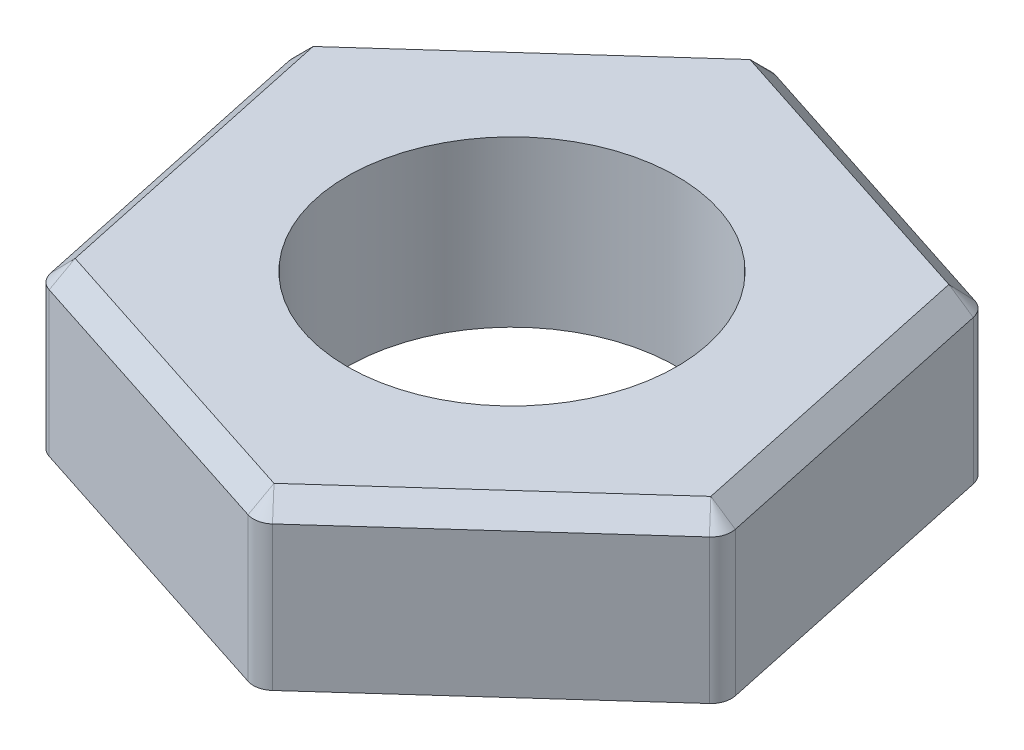
from build123d import *

# Parameters (mm, degrees)
BOSS_EXTRUDE1_DEPTH     = 4
FILLET1_R               = 0.5
CHAMFER1_SIZE           = 0.5
CUT_EXTRUDE1_DEPTH      = 4
CUT_EXTRUDE1_DEPTH_BACK = 4
SKETCH2_R               = 4


with BuildPart() as part:
    # Sketch1 → Boss-Extrude1 (new body)
    with BuildSketch(Plane(origin=(0, 0, 0), x_dir=(1, 0, 0), z_dir=(0, 1, 0))):
        Polygon((6.003079224, 5.412612415), (-1.68592024, 7.905125317), (-7.688999465, 2.492512902), (-6.003079224, -5.412612415), (1.68592024, -7.905125317), (7.688999465, -2.492512902), align=None)
    extrude(amount=BOSS_EXTRUDE1_DEPTH)

    # Fillet1
    fillet1_edges = [part.edges().sort_by_distance(p)[0] for p in [
        (7.688999465, 2, 2.492512902),
        (-6.003079224, 2, 5.412612415),
        (-7.688999465, 2, -2.492512902),
        (-1.68592024, 2, -7.905125317),
        (6.003079224, 2, -5.412612415),
        (1.68592024, 2, 7.905125317),
    ]]
    fillet(fillet1_edges, radius=FILLET1_R)

    # Chamfer1
    chamfer1_edges = [part.edges().sort_by_distance(p)[0] for p in [
        (2.158579492, 4, -6.658868866),
        (-1.669786634, 4, -7.829476319),
        (5.945632073, 4, -5.360815804),
        (-4.687459853, 4, -5.198819109),
        (6.846039345, 4, -1.460049757),
        (-7.615418708, 4, -2.468660515),
        (7.615418708, 4, 2.468660515),
        (-6.846039345, 4, 1.460049757),
        (4.687459853, 4, 5.198819109),
        (-5.945632073, 4, 5.360815804),
        (1.669786634, 4, 7.829476319),
        (-2.158579492, 4, 6.658868866),
    ]]
    chamfer(chamfer1_edges, length=CHAMFER1_SIZE)

    # Sketch2 → Cut-Extrude1 (cut, two sides: drawn at the far end of the back side and taken through both)
    with BuildSketch(Plane(origin=(0, 4, 0), x_dir=(1, 0, 0), z_dir=(0, 1, 0)).offset(-CUT_EXTRUDE1_DEPTH_BACK)):
        Circle(SKETCH2_R)
    extrude(amount=CUT_EXTRUDE1_DEPTH + CUT_EXTRUDE1_DEPTH_BACK, mode=Mode.SUBTRACT)


solid = part.part
